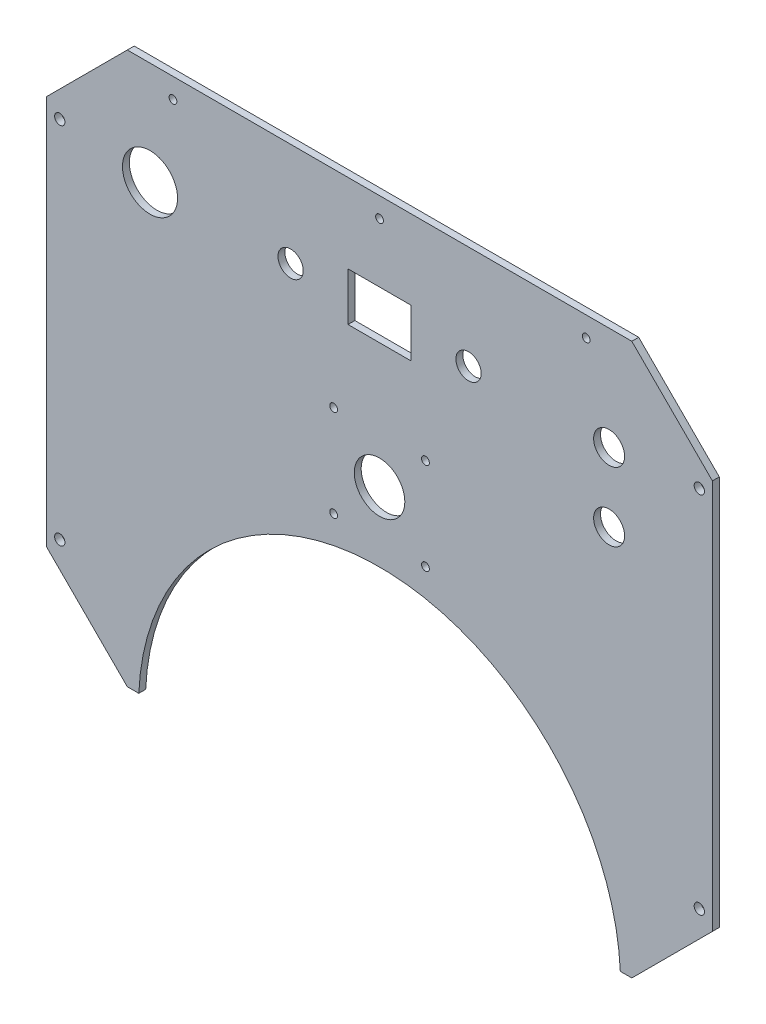
from build123d import *

# Parameters (mm, degrees)
BOSS_EXTRU_1_DEPTH      = 3
D_GAGEMENT_M42_D        = 4.5
D_GAGEMENT_M42_DEPTH    = 10
D_GAGEMENT_M42_TIP      = 1.351936393
D_GAGEMENT_M221_D       = 24
D_GAGEMENT_M221_DEPTH   = 10
D_GAGEMENT_M221_TIP     = 7.210327428
D_GAGEMENT_M121_D       = 13.5
D_GAGEMENT_M121_DEPTH   = 10
D_GAGEMENT_M121_TIP     = 4.055809178
D_GAGEMENT_M101_D       = 11
D_GAGEMENT_M101_DEPTH   = 10
D_GAGEMENT_M101_TIP     = 3.304733405
ESQUISSE26_W            = 27.5
ESQUISSE26_H            = 21
ENL_V_MAT_EXTRU_1_DEPTH = 10
D_GAGEMENT_M31_D        = 3.4
D_GAGEMENT_M201_D       = 22
D_GAGEMENT_M33_D        = 3.4


with BuildPart() as part:
    # Esquisse1 → Boss.-Extru.1 (new body)
    with BuildSketch(Plane.XY):
        with BuildLine():
            Line((-145, 85), (-109.886246, 120.113754))
            Line((-109.886246, 120.113754), (109.886246, 120.113754))
            Line((109.886246, 120.113754), (145, 85))
            Line((145, 85), (145, -85))
            Line((145, -85), (109.886246, -120.113754))
            Line((109.886246, -120.113754), (104.886246, -120.113754))
            ThreePointArc((104.886246, -120.113754), (0, -20), (-104.886246, -120.113754))
            Line((-104.886246, -120.113754), (-109.886246, -120.113754))
            Line((-109.886246, -120.113754), (-145, -85))
            Line((-145, -85), (-145, 85))
        make_face()
    extrude(amount=BOSS_EXTRU_1_DEPTH)

    # Dégagement M42
    with Locations(Plane.XY.offset(3)):
        with Locations((-139.3, 79.3), (-139.3, -79.3), (139.3, -79.3), (139.3, 79.3)):
            Hole(D_GAGEMENT_M42_D / 2, depth=D_GAGEMENT_M42_DEPTH)
            with Locations((0, 0, -(D_GAGEMENT_M42_DEPTH + D_GAGEMENT_M42_TIP / 2))):  # 118° drill point
                Cone(0, D_GAGEMENT_M42_D / 2, D_GAGEMENT_M42_TIP, mode=Mode.SUBTRACT)

    # Dégagement M221
    with Locations(Plane.XY.offset(3)):
        with Locations((-100, 75.113754)):
            Hole(D_GAGEMENT_M221_D / 2, depth=D_GAGEMENT_M221_DEPTH)
            with Locations((0, 0, -(D_GAGEMENT_M221_DEPTH + D_GAGEMENT_M221_TIP / 2))):  # 118° drill point
                Cone(0, D_GAGEMENT_M221_D / 2, D_GAGEMENT_M221_TIP, mode=Mode.SUBTRACT)

    # Dégagement M121
    with Locations(Plane.XY.offset(3)):
        with Locations((100, 75.113754), (100, 45.113754)):
            Hole(D_GAGEMENT_M121_D / 2, depth=D_GAGEMENT_M121_DEPTH)
            with Locations((0, 0, -(D_GAGEMENT_M121_DEPTH + D_GAGEMENT_M121_TIP / 2))):  # 118° drill point
                Cone(0, D_GAGEMENT_M121_D / 2, D_GAGEMENT_M121_TIP, mode=Mode.SUBTRACT)

    # Dégagement M101
    with Locations(Plane.XY.offset(3)):
        with Locations((-38.75, 75.113754), (38.75, 75.113754)):
            Hole(D_GAGEMENT_M101_D / 2, depth=D_GAGEMENT_M101_DEPTH)
            with Locations((0, 0, -(D_GAGEMENT_M101_DEPTH + D_GAGEMENT_M101_TIP / 2))):  # 118° drill point
                Cone(0, D_GAGEMENT_M101_D / 2, D_GAGEMENT_M101_TIP, mode=Mode.SUBTRACT)

    # Esquisse26 → Enlèv. mat.-Extru.1 (cut)
    with BuildSketch(Plane.XY.offset(3)):
        with Locations((0, 75.113754)):
            Rectangle(ESQUISSE26_W, ESQUISSE26_H)
    extrude(amount=-ENL_V_MAT_EXTRU_1_DEPTH, mode=Mode.SUBTRACT)

    # Dégagement M31 (through all)
    with Locations(Plane.XY.offset(3)):
        with Locations((0, 111.413754), (-90, 111.413754), (90, 111.413754)):
            Hole(D_GAGEMENT_M31_D / 2)

    # Dégagement M201 (through all)
    with Locations(Plane.XY.offset(3)):
        with Locations((0, 10.113754)):
            Hole(D_GAGEMENT_M201_D / 2)

    # Dégagement M33 (through all)
    with Locations(Plane.XY.offset(3)):
        with Locations((-20, 30.113754), (20, 30.113754), (20, -9.886246), (-20, -9.886246)):
            Hole(D_GAGEMENT_M33_D / 2)


solid = part.part
